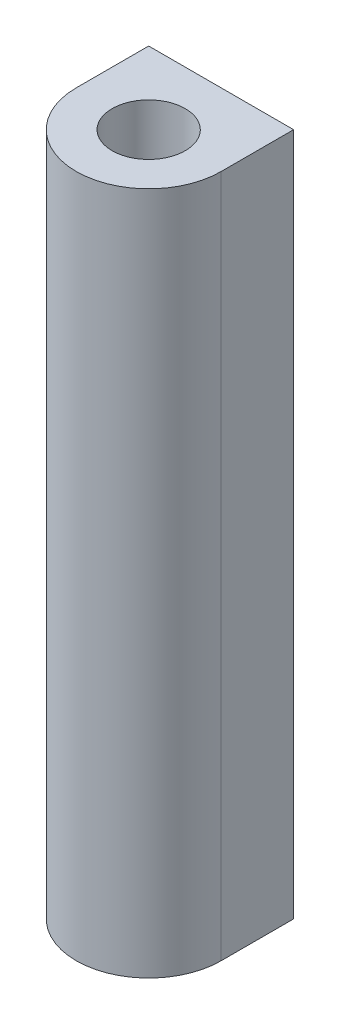
from build123d import *

# Parameters (mm, degrees)
SKETCH1_R           = 3.025
BOSS_EXTRUDE1_DEPTH = 56.6


with BuildPart() as part:
    # Sketch1 → Boss-Extrude1 (new body)
    with BuildSketch(Plane(origin=(0, 0, 0), x_dir=(1, 0, 0), z_dir=(0, 1, 0))):
        with BuildLine():
            Line((-6, 0), (-6, 5.43))
            Line((-6, 5.43), (-6, 6))
            Line((-6, 6), (6, 6))
            Line((6, 6), (6, 5.43))
            Line((6, 5.43), (6, 0))
            ThreePointArc((6, 0), (0, -6), (-6, 0))
        make_face()
        Circle(SKETCH1_R, mode=Mode.SUBTRACT)
    extrude(amount=BOSS_EXTRUDE1_DEPTH)


solid = part.part
